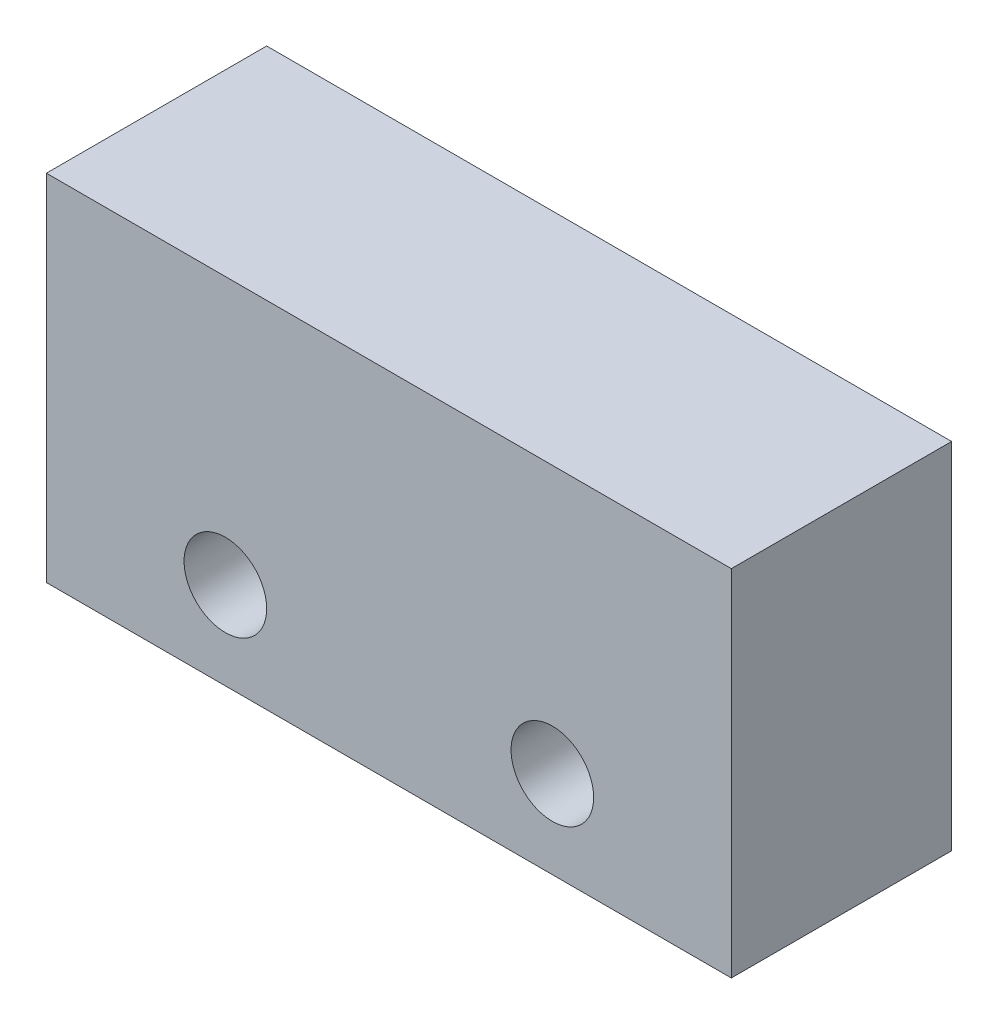
from build123d import *

# Parameters (mm, degrees)
SKETCH1_W           = 19.9
SKETCH1_H           = 10.3
SKETCH1_R           = 1.2
BOSS_EXTRUDE1_DEPTH = 6.4


with BuildPart() as part:
    # Sketch1 → Boss-Extrude1 (new body)
    with BuildSketch(Plane.XY):
        Rectangle(SKETCH1_W, SKETCH1_H)
        with Locations((-4.75, -2.61)):
            Circle(SKETCH1_R, mode=Mode.SUBTRACT)
        with Locations((4.75, -2.61)):
            Circle(SKETCH1_R, mode=Mode.SUBTRACT)
    extrude(amount=BOSS_EXTRUDE1_DEPTH)


solid = part.part
